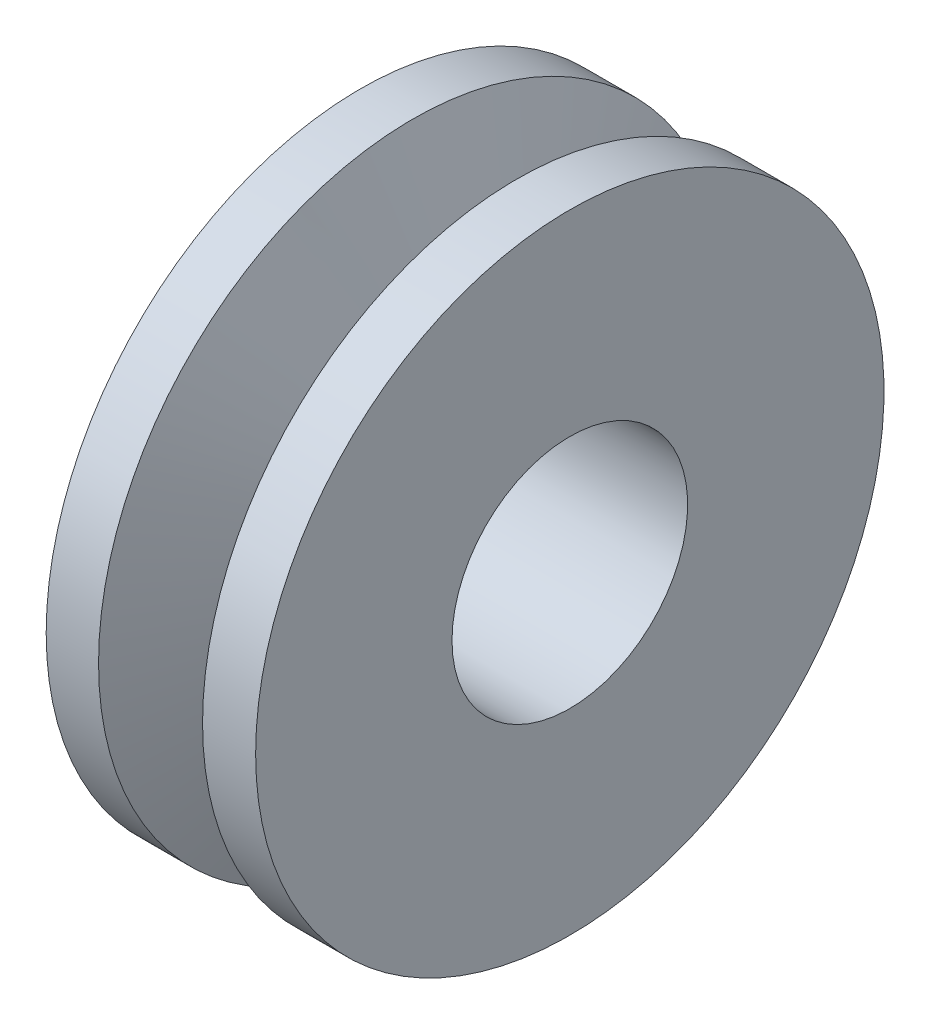
from build123d import *


with BuildPart() as part:
    # Sketch1 → Revolve1 (revolve)
    with BuildSketch(Plane.XY):
        Polygon((-5, 5.625), (-5, 15), (-2.5, 15), (0, 9.006195009), (2.465465809, 15), (5, 15), (5, 5.625), align=None)
    revolve(axis=Axis((-5, 0, 0), (1, 0, 0)))


solid = part.part
